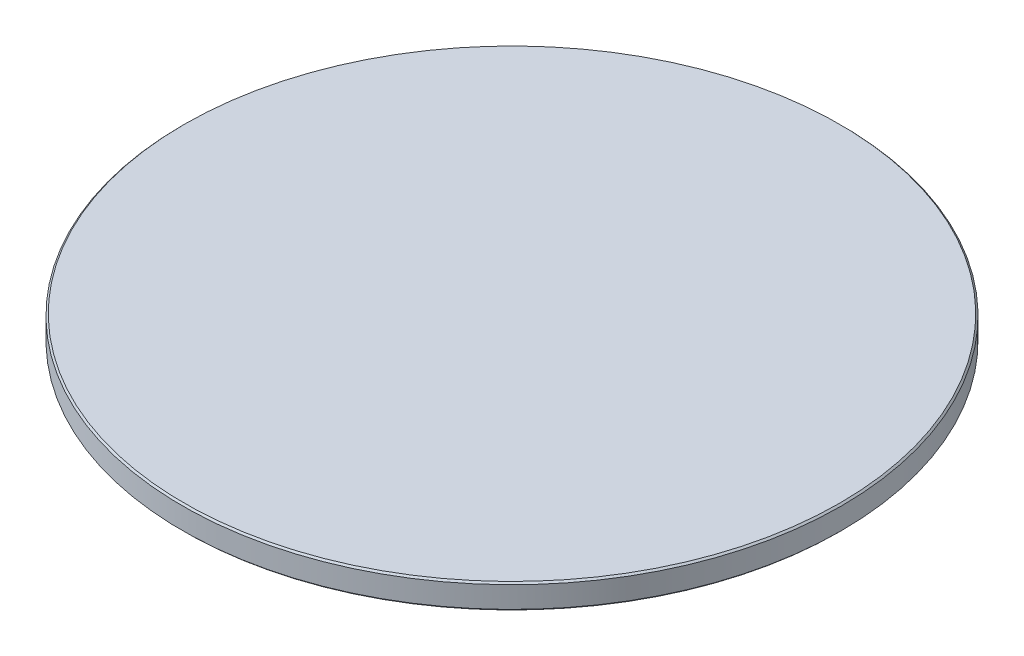
from build123d import *


with BuildPart() as part:
    # Schizzo1 → Rivoluzione1 (revolve)
    with BuildSketch(Plane.XY):
        Polygon((0, 3), (0, 0), (-39.8, 0), (-40, 0.2), (-40, 2.8), (-39.8, 3), align=None)
    revolve(axis=Axis((0, 3, 0), (0, -1, 0)))


solid = part.part
